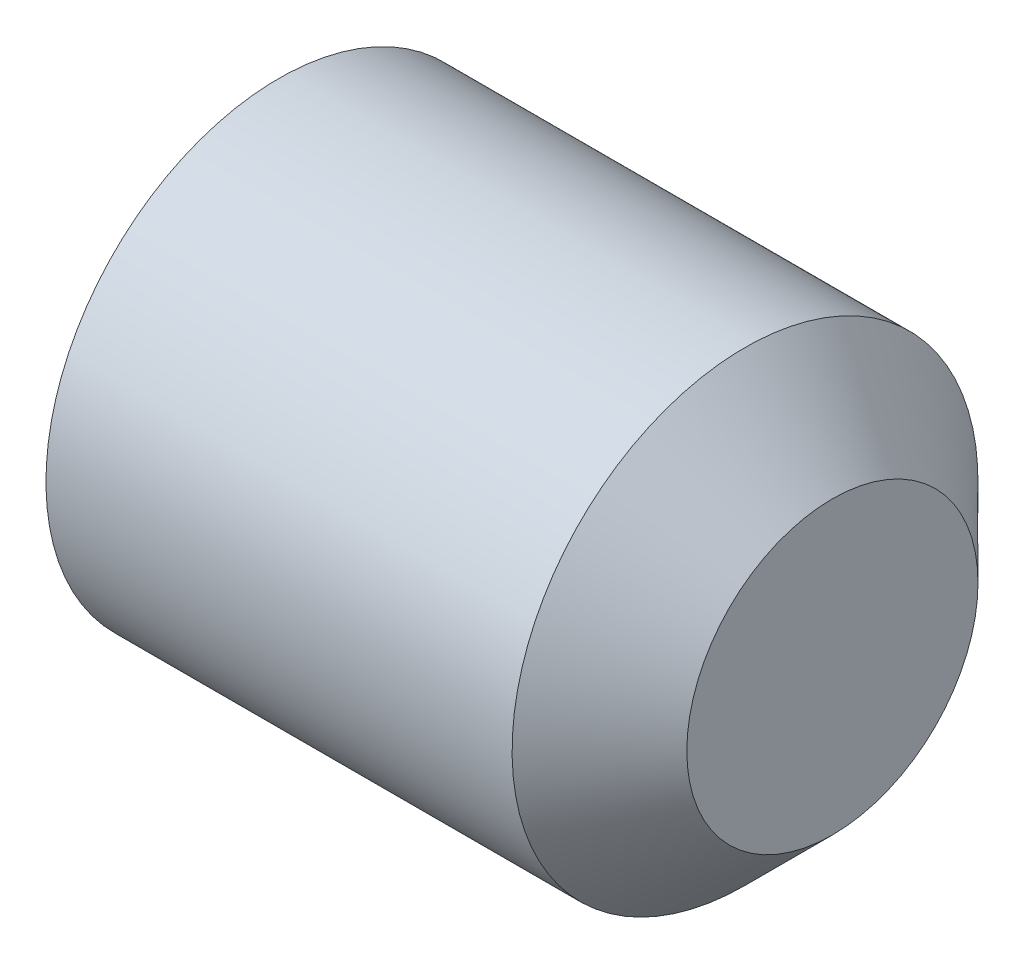
from build123d import *

# Parameters (mm, degrees)
CUT_EXTRUDE1_DEPTH = 1.5


with BuildPart() as part:
    # Sketch1 → Revolve1 (revolve)
    with BuildSketch(Plane.XY):
        Polygon((5, 0), (5, -1.25), (4.25, -2), (0.247971941, -2), (0, -1.5705), (0, -1.154700538), (0.666666667, 0), align=None)
    revolve(axis=Axis((0.666666667, 0, 0), (1, 0, 0)))

    # Sketch2 → Cut-Extrude1 (cut)
    with BuildSketch(Plane(origin=(0, 0, 0), x_dir=(0, 0, -1), z_dir=(1, 0, 0))):
        Polygon((-1.154700538, 0), (-0.577350269, -1), (0.577350269, -1), (1.154700538, 0), (0.577350269, 1), (-0.577350269, 1), align=None)
    extrude(amount=CUT_EXTRUDE1_DEPTH, mode=Mode.SUBTRACT)


solid = part.part
